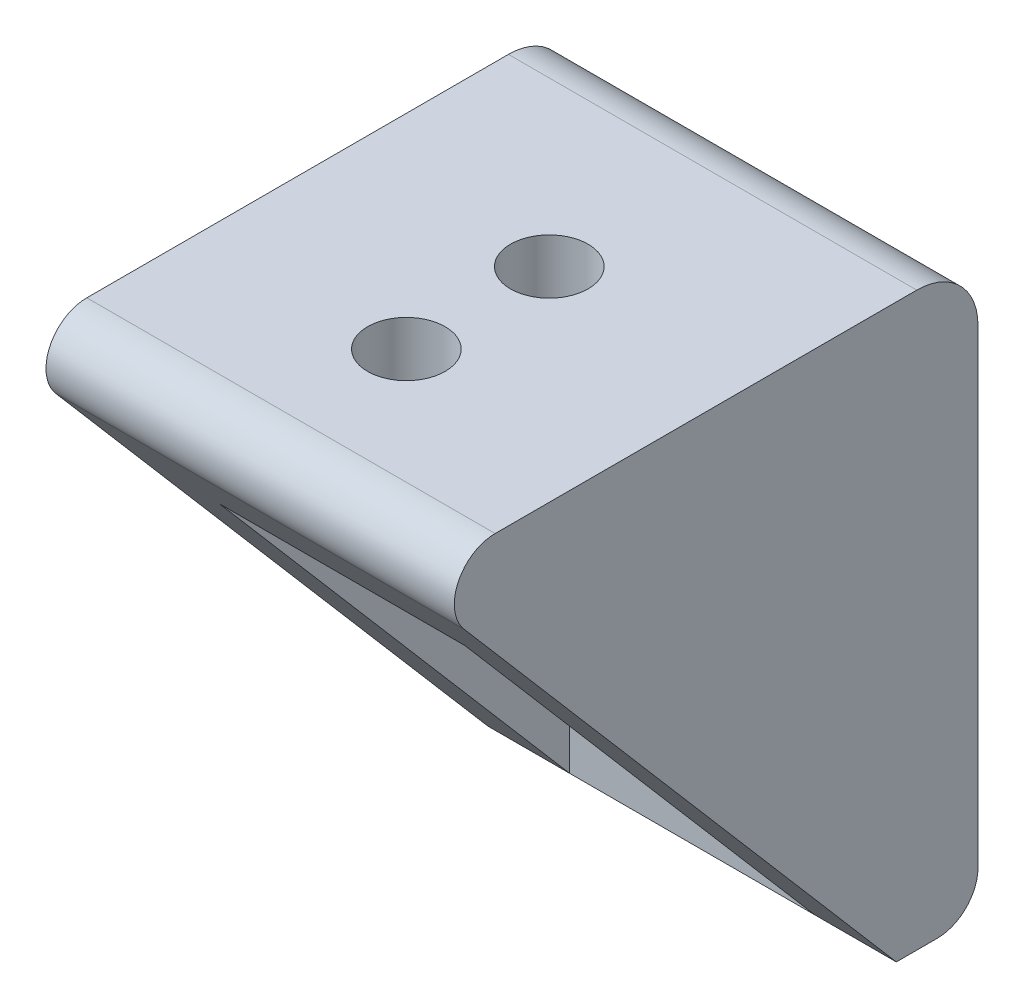
from build123d import *

# Parameters (mm, degrees)
SKETCH1_W               = 20
SKETCH1_H               = 28
BOSS_EXTRUDE1_DEPTH     = 28
SKETCH2_W               = 24
SKETCH2_H               = 20
CUT_EXTRUDE1_DEPTH      = 6
CUT_EXTRUDE1_DEPTH_BACK = 6
CUT_EXTRUDE2_DEPTH      = 20
FILLET1_R               = 2
SKETCH4_R               = 1.9
CUT_EXTRUDE3_DEPTH      = 10
SKETCH5_R               = 1.9
CUT_EXTRUDE4_DEPTH      = 5
FILLET2_R               = 2
FILLET3_R               = 3


with BuildPart() as part:
    # Sketch1 → Boss-Extrude1 (new body)
    with BuildSketch(Plane.XY):
        Rectangle(SKETCH1_W, SKETCH1_H)
    extrude(amount=BOSS_EXTRUDE1_DEPTH)

    # Sketch2 → Cut-Extrude1 (cut, two sides)
    with BuildSketch(Plane.ZY) as cut_extrude1_sk:
        with Locations((16, -4)):
            Rectangle(SKETCH2_W, SKETCH2_H)
    extrude(amount=CUT_EXTRUDE1_DEPTH, mode=Mode.SUBTRACT)
    extrude(cut_extrude1_sk.sketch, amount=-CUT_EXTRUDE1_DEPTH_BACK, mode=Mode.SUBTRACT)

    # Sketch3 → Cut-Extrude2 (cut)
    with BuildSketch(Plane.ZY.offset(10)):
        Polygon((28, 14), (4, -14), (28, -14), align=None)
    extrude(amount=-CUT_EXTRUDE2_DEPTH, mode=Mode.SUBTRACT)

    # Fillet1
    fillet1_edges = [part.edges().sort_by_distance(p)[0] for p in [
        (0, 14, 28),
    ]]
    fillet(fillet1_edges, radius=FILLET1_R)

    # Sketch4 → Cut-Extrude3 (cut)
    with BuildSketch(Plane(origin=(0, 14, 0), x_dir=(1, 0, 0), z_dir=(0, 1, 0))):
        with Locations((0, -11)):
            Circle(SKETCH4_R)
        with Locations((0, -18)):
            Circle(SKETCH4_R)
    extrude(amount=-CUT_EXTRUDE3_DEPTH, mode=Mode.SUBTRACT)

    # Sketch5 → Cut-Extrude4 (cut, through all)
    with BuildSketch(Plane.XY.offset(4)):
        with Locations((0, -2)):
            Circle(SKETCH5_R)
        with Locations((0, -10)):
            Circle(SKETCH5_R)
    extrude(amount=-CUT_EXTRUDE4_DEPTH, mode=Mode.SUBTRACT)

    # Fillet2
    fillet2_edges = [part.edges().sort_by_distance(p)[0] for p in [
        (0, -14, 0),
    ]]
    fillet(fillet2_edges, radius=FILLET2_R)

    # Fillet3
    fillet3_edges = [part.edges().sort_by_distance(p)[0] for p in [
        (0, 14, 0),
    ]]
    fillet(fillet3_edges, radius=FILLET3_R)


solid = part.part
